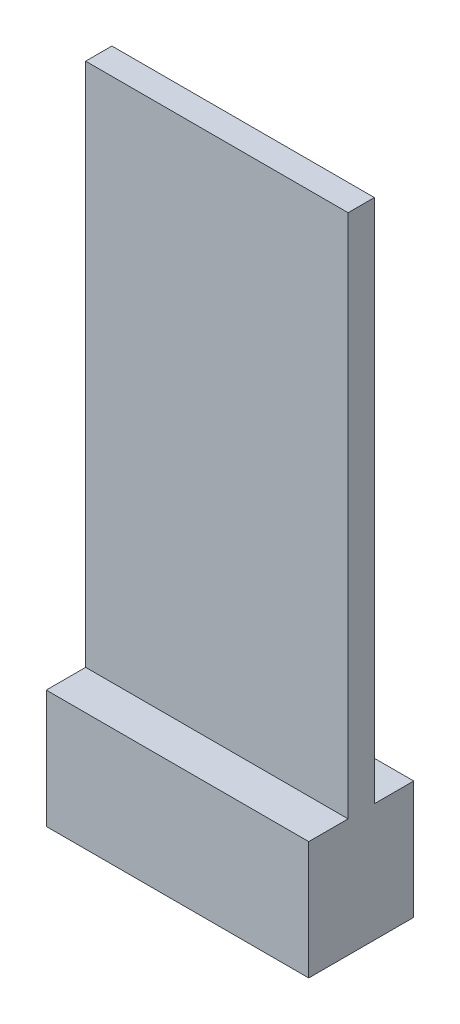
from build123d import *

# Parameters (mm, degrees)
SKETCH2_W           = 20
SKETCH2_H           = 9
BOSS_EXTRUDE1_DEPTH = 8
SKETCH3_W           = 4
SKETCH3_H           = 5
CUT_EXTRUDE1_DEPTH  = 10
SKETCH6_W           = 20
SKETCH6_H           = 2
BOSS_EXTRUDE3_DEPTH = 40


with BuildPart() as part:
    # Sketch2 → Boss-Extrude1 (new body)
    with BuildSketch(Plane.XY):
        Rectangle(SKETCH2_W, SKETCH2_H)
    extrude(amount=BOSS_EXTRUDE1_DEPTH)

    # Sketch3 → Cut-Extrude1 (cut)
    with BuildSketch(Plane.ZY.offset(10)):
        with Locations((4, 0)):
            Rectangle(SKETCH3_W, SKETCH3_H)
    extrude(amount=-CUT_EXTRUDE1_DEPTH, mode=Mode.SUBTRACT)

    # Sketch6 → Boss-Extrude3 (add)
    with BuildSketch(Plane(origin=(0, 4.5, 0), x_dir=(1, 0, 0), z_dir=(0, 1, 0))):
        with Locations((0, -4)):
            Rectangle(SKETCH6_W, SKETCH6_H)
    extrude(amount=BOSS_EXTRUDE3_DEPTH)


solid = part.part
